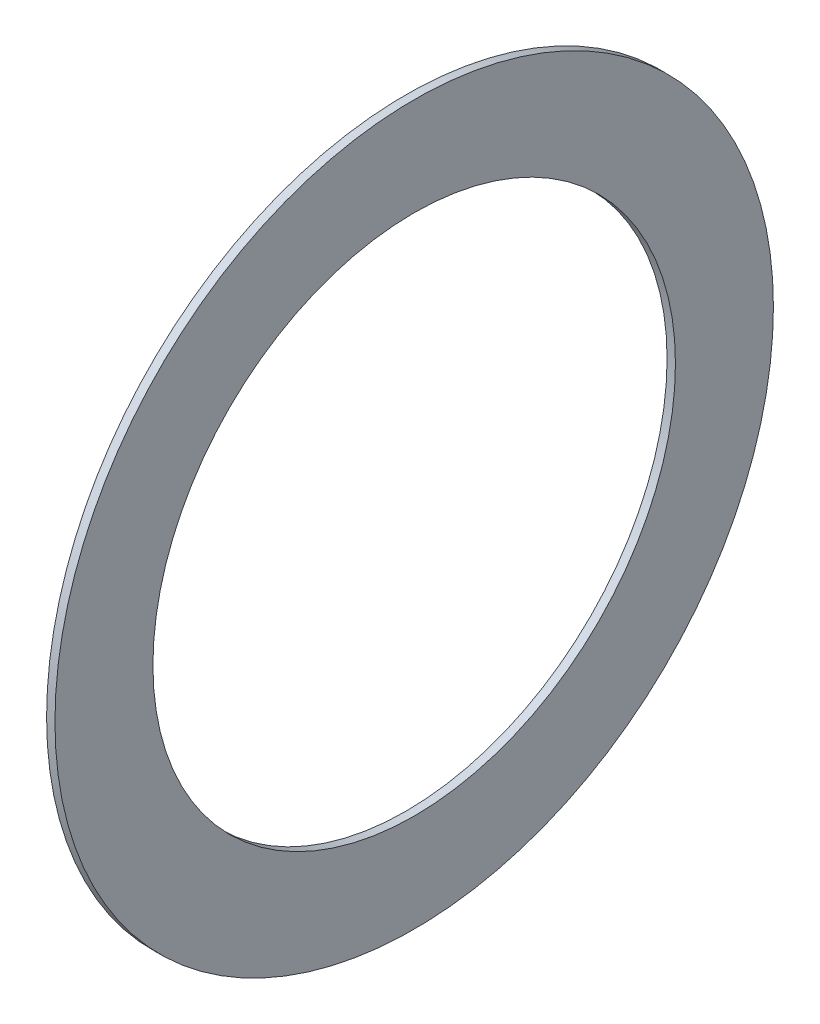
from build123d import *

# Parameters (mm, degrees)
SKETCH1_R      = 34.925
SKETCH1_R_2    = 25.4
EXTRUDE1_DEPTH = 0.8128


with BuildPart() as part:
    # Sketch1 → Extrude1 (new body)
    with BuildSketch(Plane(origin=(0, 0, 0), x_dir=(0, 0, -1), z_dir=(1, 0, 0))):
        Circle(SKETCH1_R)
        Circle(SKETCH1_R_2, mode=Mode.SUBTRACT)
    extrude(amount=EXTRUDE1_DEPTH)


solid = part.part
